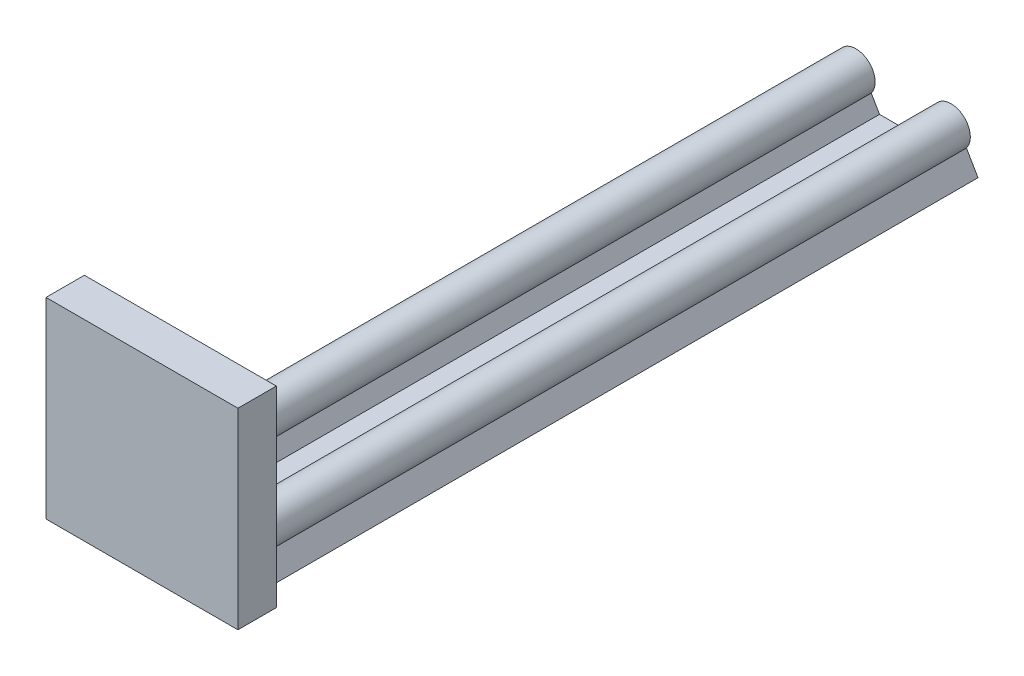
from build123d import *

# Parameters (mm, degrees)
BOSS_EXTRUDE1_DEPTH   = 220
BOSS_EXTRUDE1_2_DEPTH = 220
BOSS_EXTRUDE4_DEPTH   = 220
SKETCH5_R             = 1.37
CUT_EXTRUDE1_DEPTH    = 7
CUT_EXTRUDE2_START    = -7
SKETCH6_R             = 1.37
CUT_EXTRUDE2_DEPTH    = 7
CUT_EXTRUDE4_DEPTH    = 10.8
CUT_EXTRUDE5_START    = -10.8
CUT_EXTRUDE5_DEPTH    = 10.8
SKETCH11_R            = 2
CUT_EXTRUDE6_DEPTH    = 7
SKETCH12_R            = 1.5
CUT_EXTRUDE7_DEPTH    = 7
SKETCH13_W            = 50
SKETCH13_H            = 50
BOSS_EXTRUDE5_DEPTH   = 10
SKETCH14_R            = 5
CUT_EXTRUDE8_DEPTH    = 5
SKETCH4_2_R           = 3.2
CUT_EXTRUDE9_DEPTH    = 5


with BuildPart() as part:
    # Sketch1 → Boss-Extrude1 (new body)
    with BuildSketch(Plane.XY):
        with BuildLine():
            Line((-4, -3), (-7, -8.196152423))
            Line((-7, -8.196152423), (7, -8.196152423))
            Line((7, -8.196152423), (4, -3))
            ThreePointArc((4, -3), (0, 5), (-4, -3))
        make_face()
    extrude(amount=BOSS_EXTRUDE1_DEPTH)



with BuildPart() as body_2:
    # Sketch1 → Boss-Extrude1 2 (new body)
    with BuildSketch(Plane.XY):
        with BuildLine():
            Line((31.8, -8.196152423), (28.8, -3))
            ThreePointArc((28.8, -3), (24.8, 5), (20.8, -3))
            Line((20.8, -3), (17.8, -8.196152423))
            Line((17.8, -8.196152423), (31.8, -8.196152423))
        make_face()
    extrude(amount=BOSS_EXTRUDE1_2_DEPTH)


with BuildPart() as part_1:
    add(part.part)

    add(body_2.part)  # Boss-Extrude4 merges body 2
    # Sketch3 → Boss-Extrude4 (add)
    with BuildSketch(Plane.XY.offset(220)):
        Polygon((7, -8.196152423), (17.8, -8.196152423), (18.65, -8.196152423), (18.65, -6.723909236), (6.15, -6.723909236), (6.15, -8.196152423), align=None)
    extrude(amount=-BOSS_EXTRUDE4_DEPTH)

    # Sketch5 → Cut-Extrude1 (cut)
    with BuildSketch(Plane(origin=(0, 0, 0), x_dir=(-1, 0, 0), z_dir=(0, 0, -1))):
        Circle(SKETCH5_R)
        with Locations((-24.8, 0)):
            Circle(SKETCH5_R)
    extrude(amount=-CUT_EXTRUDE1_DEPTH, mode=Mode.SUBTRACT)

    # Sketch6 → Cut-Extrude2 (cut)
    with BuildSketch(Plane.XY.offset(220).offset(CUT_EXTRUDE2_START)):
        Circle(SKETCH6_R)
        with Locations((24.8, 0)):
            Circle(SKETCH6_R)
    extrude(amount=CUT_EXTRUDE2_DEPTH, mode=Mode.SUBTRACT)

    # Sketch9 → Cut-Extrude4 (cut)
    with BuildSketch(Plane(origin=(0, 0, 0), x_dir=(-1, 0, 0), z_dir=(0, 0, -1))):
        with BuildLine():
            Line((-28.8, -3), (-31.8, -8.196152423))
            Line((-31.8, -8.196152423), (7, -8.196152423))
            Line((7, -8.196152423), (4, -3))
            ThreePointArc((4, -3), (0, 5), (-4, -3))
            Line((-4, -3), (-6.15, -6.723909236))
            Line((-6.15, -6.723909236), (-18.65, -6.723909236))
            Line((-18.65, -6.723909236), (-20.8, -3))
            ThreePointArc((-20.8, -3), (-24.8, 5), (-28.8, -3))
        make_face()
    extrude(amount=-CUT_EXTRUDE4_DEPTH, mode=Mode.SUBTRACT)

    # Sketch10 → Cut-Extrude5 (cut)
    with BuildSketch(Plane.XY.offset(220).offset(CUT_EXTRUDE5_START)):
        with BuildLine():
            Line((20.8, -3), (18.65, -6.723909236))
            Line((18.65, -6.723909236), (6.15, -6.723909236))
            Line((6.15, -6.723909236), (4, -3))
            ThreePointArc((4, -3), (0, 5), (-4, -3))
            Line((-4, -3), (-7, -8.196152423))
            Line((-7, -8.196152423), (31.8, -8.196152423))
            Line((31.8, -8.196152423), (28.8, -3))
            ThreePointArc((28.8, -3), (24.8, 5), (20.8, -3))
        make_face()
    extrude(amount=CUT_EXTRUDE5_DEPTH, mode=Mode.SUBTRACT)

    # Sketch11 → Cut-Extrude6 (cut)
    with BuildSketch(Plane.XY.offset(209.2)):
        Circle(SKETCH11_R)
        with Locations((24.8, 0)):
            Circle(SKETCH11_R)
    extrude(amount=-CUT_EXTRUDE6_DEPTH, mode=Mode.SUBTRACT)

    # Sketch12 → Cut-Extrude7 (cut)
    with BuildSketch(Plane(origin=(0, 0, 10.8), x_dir=(-1, 0, 0), z_dir=(0, 0, -1))):
        Circle(SKETCH12_R)
        with Locations((-24.8, 0)):
            Circle(SKETCH12_R)
    extrude(amount=-CUT_EXTRUDE7_DEPTH, mode=Mode.SUBTRACT)

    # Sketch13 → Boss-Extrude5 (add)
    with BuildSketch(Plane.XY.offset(209.2)):
        with Locations((12.4, 16.803847577)):
            Rectangle(SKETCH13_W, SKETCH13_H)
    extrude(amount=-BOSS_EXTRUDE5_DEPTH)

    # Sketch14 → Cut-Extrude8 (cut)
    with BuildSketch(Plane(origin=(0, 0, 199.2), x_dir=(-1, 0, 0), z_dir=(0, 0, -1))):
        with Locations((-12.4, 22.303847577)):
            Circle(SKETCH14_R)
    extrude(amount=-CUT_EXTRUDE8_DEPTH, mode=Mode.SUBTRACT)

    # Sketch4_2 → Cut-Extrude9 (cut)
    with BuildSketch(Plane.XZ.offset(8.196152423)):
        with Locations((0, 197.5)):
            Circle(SKETCH4_2_R)
        with Locations((24.8, 197.5)):
            Circle(SKETCH4_2_R)
        with Locations((24.8, 23.2)):
            Circle(SKETCH4_2_R)
        with Locations((0, 23.2)):
            Circle(SKETCH4_2_R)
    extrude(amount=-CUT_EXTRUDE9_DEPTH, mode=Mode.SUBTRACT)


solid = part_1.part
